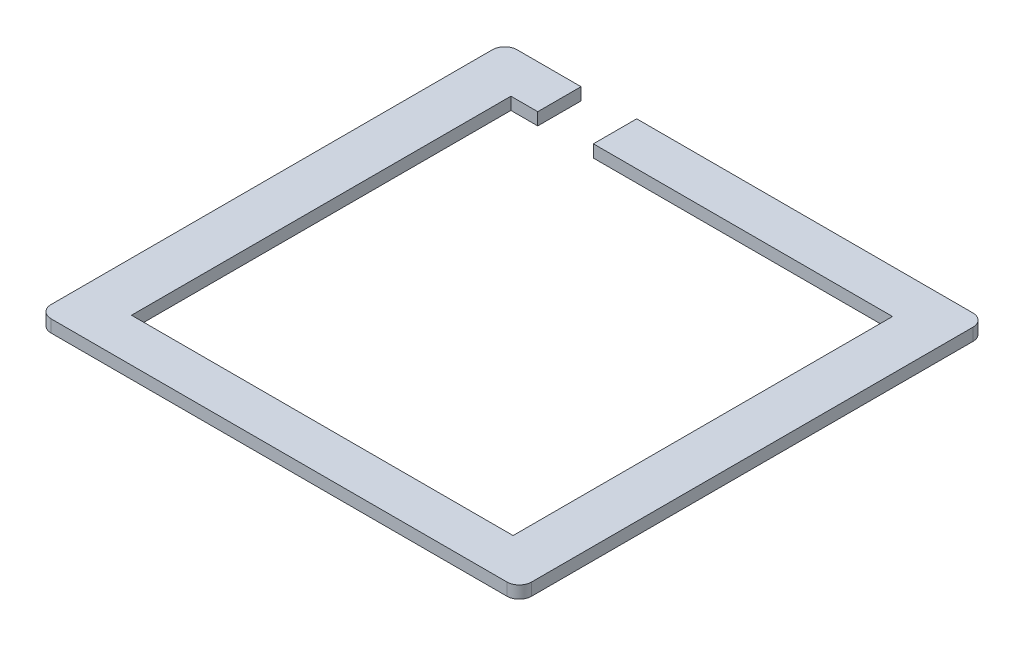
from build123d import *

# Parameters (mm, degrees)
SKETCH_1_W          = 61.702142611
SKETCH_1_H          = 61.347239899
EXTRUDE_1_DEPTH     = 2
SKETCH_2_W          = 9
SKETCH_2_H          = 7
CUT_EXTRUDE_1_DEPTH = 2


with BuildPart() as part:
    # 草图1 → 凸台-拉伸1 (new body)
    with BuildSketch(Plane(origin=(-113.392096834, -3018.473189006, -237.947347726), x_dir=(1, 0, 0), z_dir=(0, 1, 0))):
        with BuildLine():
            Line((-117.231072015, -153.924864972), (-43.528929404, -153.924864972))
            ThreePointArc((-43.528929404, -153.924864972), (-42.114715842, -154.510651409), (-41.528929404, -155.924864972))
            Line((-41.528929404, -155.924864972), (-41.528929404, -227.272104871))
            ThreePointArc((-41.528929404, -227.272104871), (-42.114715842, -228.686318433), (-43.528929404, -229.272104871))
            Line((-43.528929404, -229.272104871), (-117.231072015, -229.272104871))
            ThreePointArc((-117.231072015, -229.272104871), (-118.645285578, -228.686318433), (-119.231072015, -227.272104871))
            Line((-119.231072015, -227.272104871), (-119.231072015, -155.924864972))
            ThreePointArc((-119.231072015, -155.924864972), (-118.645285578, -154.510651409), (-117.231072015, -153.924864972))
        make_face()
        with Locations((-80.38000071, -191.598484922)):
            Rectangle(SKETCH_1_W, SKETCH_1_H, mode=Mode.SUBTRACT)
    extrude(amount=EXTRUDE_1_DEPTH)

    # 草图2 → 切除-拉伸1 (cut)
    with BuildSketch(Plane(origin=(0, -3016.473189006, 0), x_dir=(1, 0, 0), z_dir=(0, 1, 0))):
        with Locations((-215.784101988, 80.522482755)):
            Rectangle(SKETCH_2_W, SKETCH_2_H)
    extrude(amount=-CUT_EXTRUDE_1_DEPTH, mode=Mode.SUBTRACT)


solid = part.part
